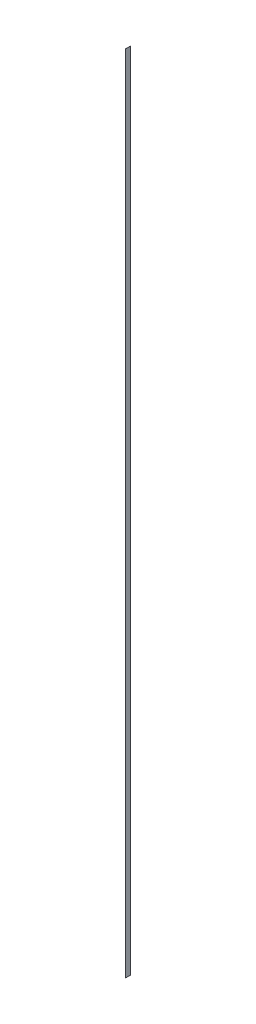
from build123d import *

# Parameters (mm, degrees)
SKETCH1_W           = 50.8
SKETCH1_H           = 8229.6
BOSS_EXTRUDE1_DEPTH = 1.27


with BuildPart() as part:
    # Sketch1 → Boss-Extrude1 (new body)
    with BuildSketch(Plane(origin=(0, 0, 0), x_dir=(0, 0, -1), z_dir=(1, 0, 0))):
        with Locations((0, 4114.8)):
            Rectangle(SKETCH1_W, SKETCH1_H)
    extrude(amount=BOSS_EXTRUDE1_DEPTH)


solid = part.part
